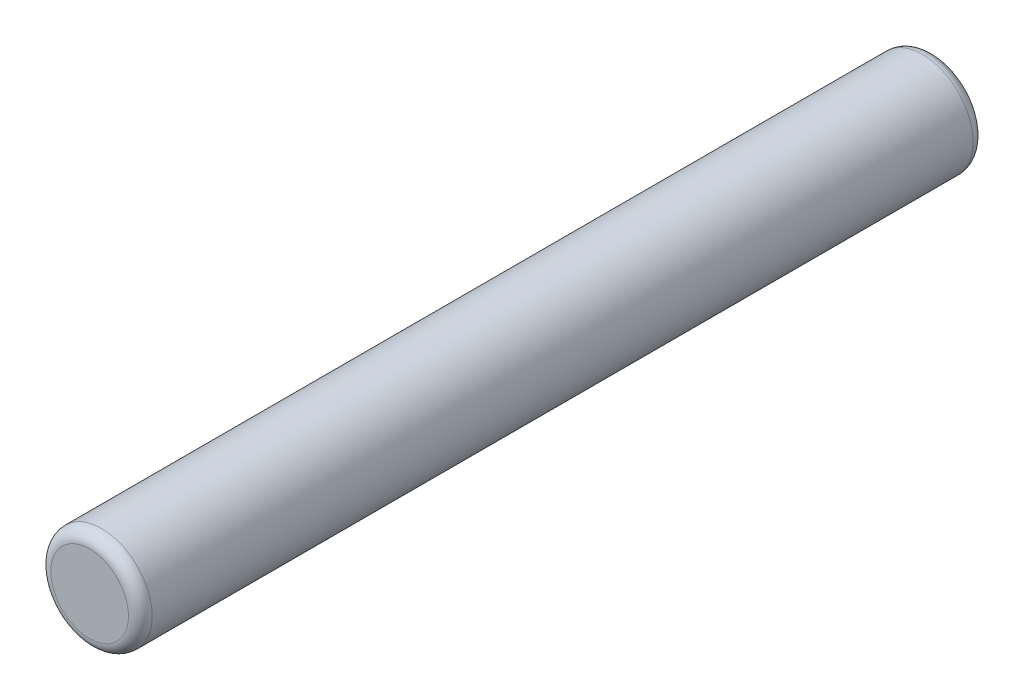
from build123d import *

# Parameters (mm, degrees)
SKETCH1_R           = 1.5
BOSS_EXTRUDE1_DEPTH = 12.5
FILLET1_R           = 0.35


with BuildPart() as part:
    # Sketch1 → Boss-Extrude1 (new body, symmetric)
    with BuildSketch(Plane.XY):
        Circle(SKETCH1_R)
    extrude(amount=BOSS_EXTRUDE1_DEPTH, both=True)

    # Fillet1
    fillet1_edges = [part.edges().sort_by_distance(p)[0] for p in [
        (-1.5, 0, -12.5),
        (-1.5, 0, 12.5),
    ]]
    fillet(fillet1_edges, radius=FILLET1_R)


solid = part.part
